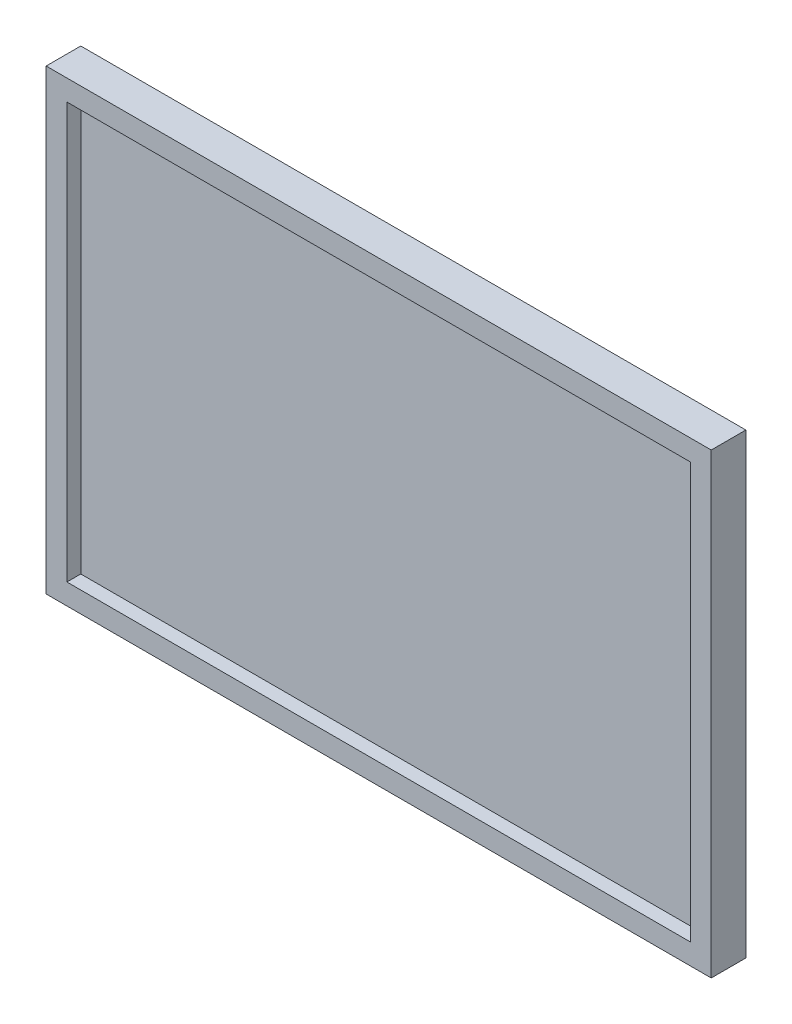
from build123d import *

# Parameters (mm, degrees)
SKETCH1_W           = 192
SKETCH1_H           = 132
BOSS_EXTRUDE1_DEPTH = 10
SKETCH2_W           = 180
SKETCH2_H           = 120
CUT_EXTRUDE1_DEPTH  = 4


with BuildPart() as part:
    # Sketch1 → Boss-Extrude1 (new body)
    with BuildSketch(Plane.XY):
        with Locations((-90, 60)):
            Rectangle(SKETCH1_W, SKETCH1_H)
    extrude(amount=BOSS_EXTRUDE1_DEPTH)

    # Sketch2 → Cut-Extrude1 (cut)
    with BuildSketch(Plane.XY.offset(10)):
        with Locations((-90, 60)):
            Rectangle(SKETCH2_W, SKETCH2_H)
    extrude(amount=-CUT_EXTRUDE1_DEPTH, mode=Mode.SUBTRACT)


solid = part.part
